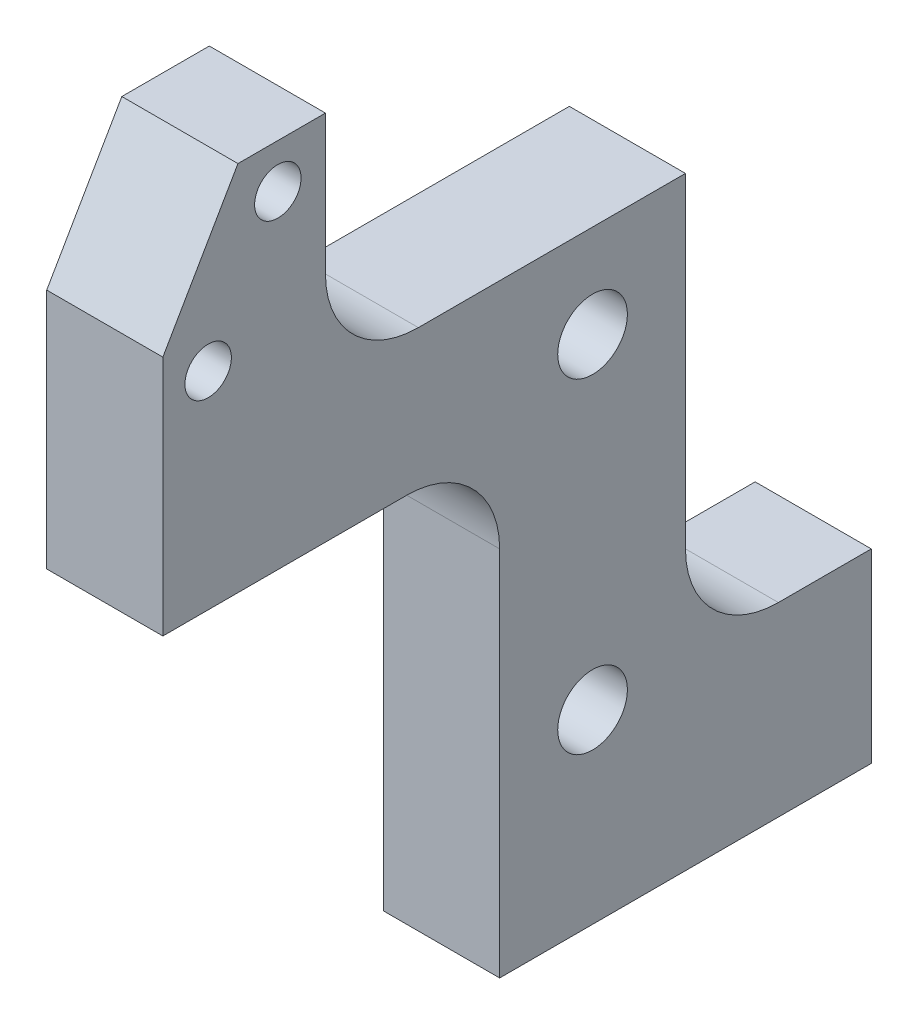
from build123d import *

# Parameters (mm, degrees)
SKETCH1_R                       = 1.5
SKETCH1_R_2                     = 1
BOSS_EXTRUDE1_DEPTH             = 5
FILLET1_R                       = 4
TAP_DRILL_FOR_M3X0_5_TAP1_D     = 2.5
TAP_DRILL_FOR_M3X0_5_TAP1_DEPTH = 4
CHAMFER1_SIZE                   = 1.5


with BuildPart() as part:
    # Sketch1 → Boss-Extrude1 (new body)
    with BuildSketch(Plane(origin=(0, 0, 0), x_dir=(0, 0, -1), z_dir=(1, 0, 0))):
        Polygon((30.5, 0), (14.5, 0), (14.5, 20), (0, 20), (0, 30.4), (3.233161507, 36), (7, 36), (7, 26), (22.5, 26), (22.5, 8), (30.5, 8), align=None)
        with Locations((18.5, 8)):
            Circle(SKETCH1_R, mode=Mode.SUBTRACT)
        with Locations((18.5, 22)):
            Circle(SKETCH1_R, mode=Mode.SUBTRACT)
        with Locations((1.95, 28.91)):
            Circle(SKETCH1_R_2, mode=Mode.SUBTRACT)
        with Locations((4.95, 34.106152423)):
            Circle(SKETCH1_R_2, mode=Mode.SUBTRACT)
    extrude(amount=BOSS_EXTRUDE1_DEPTH)

    # Fillet1
    fillet1_edges = [part.edges().sort_by_distance(p)[0] for p in [
        (2.5, 20, -14.5),
        (2.5, 26, -7),
        (2.5, 8, -22.5),
    ]]
    fillet(fillet1_edges, radius=FILLET1_R)

    # Tap Drill for M3x0.5 Tap1
    with Locations(Plane(origin=(0, 0, 0), x_dir=(-1, 0, 0), z_dir=(0, -1, 0))):
        with Locations((-2.5, 17.5), (-2.5, 27.5)):
            Hole(TAP_DRILL_FOR_M3X0_5_TAP1_D / 2, depth=TAP_DRILL_FOR_M3X0_5_TAP1_DEPTH)

    # Chamfer1
    chamfer1_edges = [part.edges().sort_by_distance(p)[0] for p in [
        (0, 8, -17),
        (0, 22, -17),
    ]]
    chamfer(chamfer1_edges, length=CHAMFER1_SIZE)


solid = part.part
